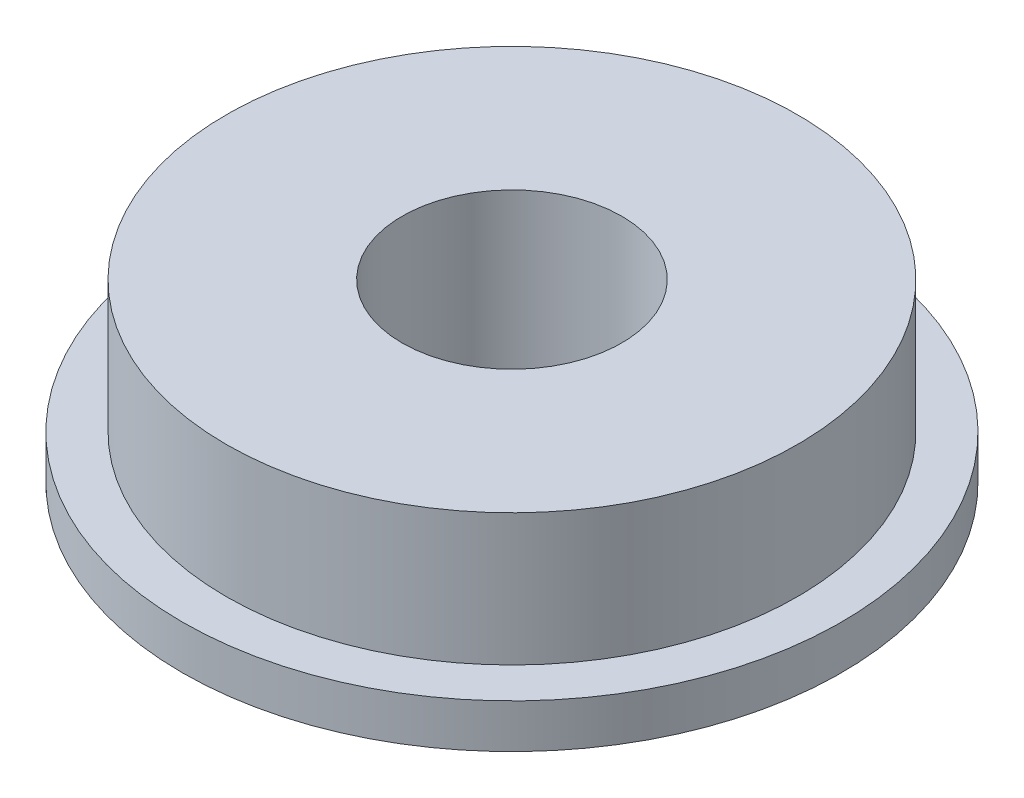
from build123d import *


with BuildPart() as part:
    # 草图1 → 旋转1 (revolve)
    with BuildSketch(Plane.XY):
        Polygon((2.5, 0), (7.5, 0), (7.5, 1), (6.5, 1), (6.5, 4), (2.5, 4), align=None)
    revolve(axis=Axis((0, 4, 0), (0, -1, 0)))


solid = part.part
